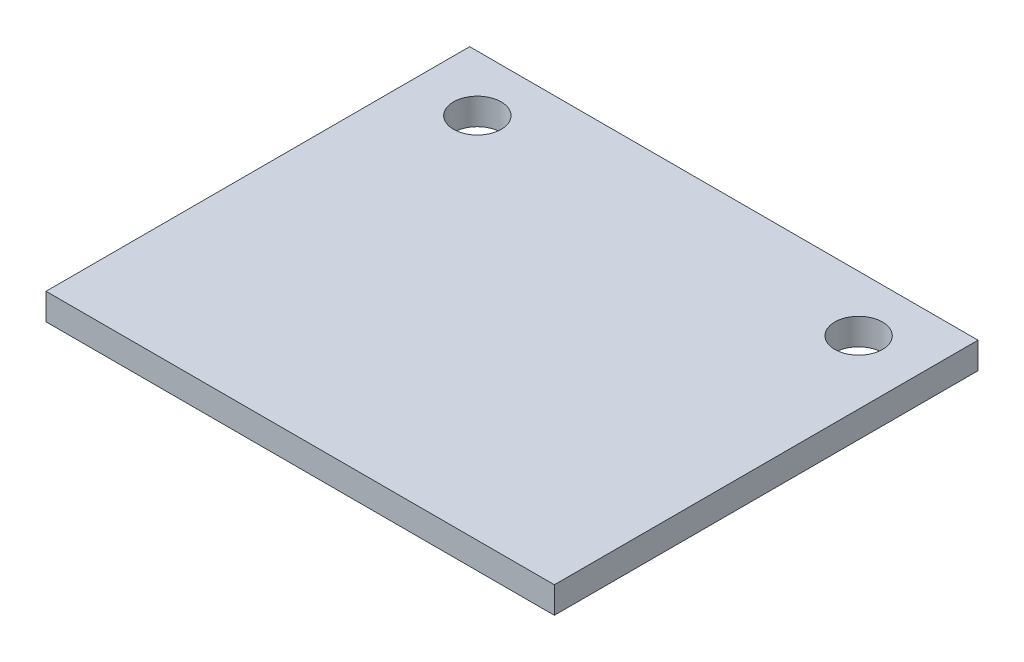
from build123d import *

# Parameters (mm, degrees)
SKETCH1_W           = 304.8
SKETCH1_H           = 266.7
SKETCH1_R           = 14.2875
BOSS_EXTRUDE1_DEPTH = 15.875
SKETCH2_W           = 304.8
SKETCH2_H           = 12.7
CUT_EXTRUDE1_DEPTH  = 16.875


with BuildPart() as part:
    # Sketch1 → Boss-Extrude1 (new body)
    with BuildSketch(Plane(origin=(0, 0, 0), x_dir=(1, 0, 0), z_dir=(0, 1, 0))):
        Rectangle(SKETCH1_W, SKETCH1_H)
        with Locations((-114.3, 87.180661253)):
            Circle(SKETCH1_R, mode=Mode.SUBTRACT)
        with Locations((114.3, 87.180661253)):
            Circle(SKETCH1_R, mode=Mode.SUBTRACT)
    extrude(amount=BOSS_EXTRUDE1_DEPTH)

    # Sketch2 → Cut-Extrude1 (cut, through all)
    with BuildSketch(Plane(origin=(0, 15.875, 0), x_dir=(1, 0, 0), z_dir=(0, 1, 0))):
        with Locations((0, 127)):
            Rectangle(SKETCH2_W, SKETCH2_H)
    extrude(amount=-CUT_EXTRUDE1_DEPTH, mode=Mode.SUBTRACT)


solid = part.part
